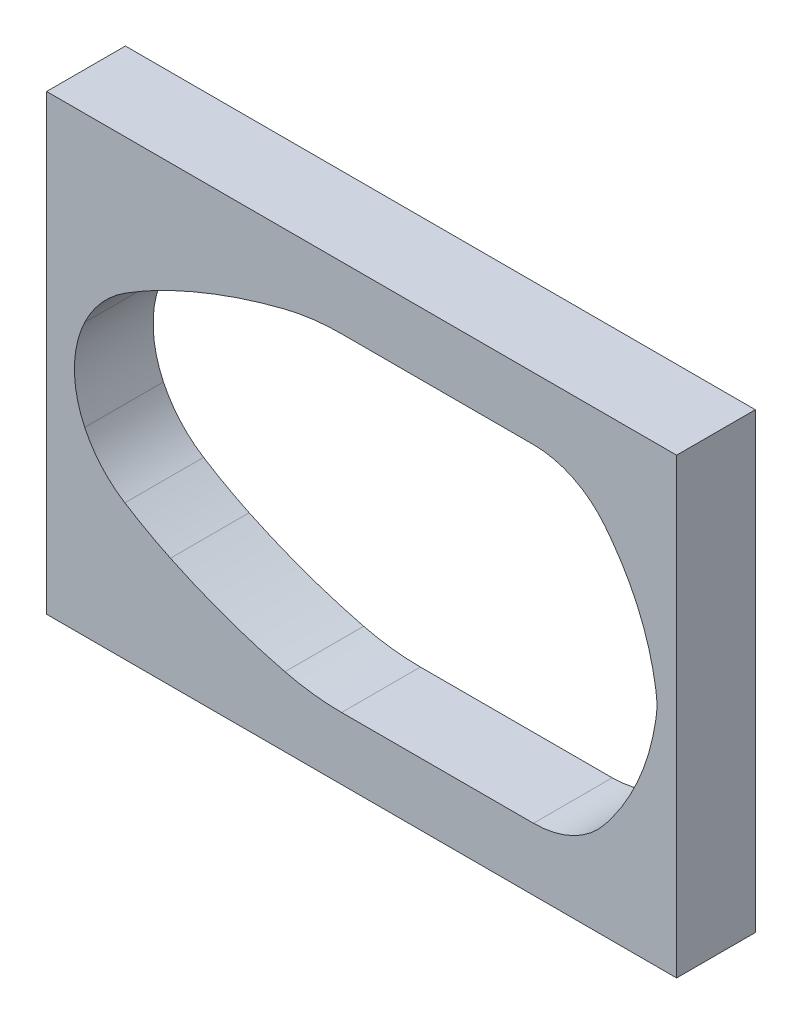
from build123d import *

# Parameters (mm, degrees)
SKETCH_4_W          = 160
SKETCH_4_H          = 115
EXTRUDE_1_DEPTH     = 20
CUT_EXTRUDE_1_DEPTH = 20
SKETCH_16_R         = 5.5
CUT_EXTRUDE_2_DEPTH = 15


with BuildPart() as part:
    # 草圖4 → 填料-伸長1 (new body)
    with BuildSketch(Plane.XY):
        with Locations((14.659712787, 72.59909222)):
            Rectangle(SKETCH_4_W, SKETCH_4_H)
    extrude(amount=EXTRUDE_1_DEPTH)

    # 草圖2 → 除料-伸長1 (cut)
    with BuildSketch(Plane.XY):
        with BuildLine():
            Line((9.582154386, 114.239387395), (32.639572719, 114.239387395))
            Line((32.639572719, 114.239387395), (35.911975242, 114.239387395))
            Line((35.911975242, 114.239387395), (58.302252446, 114.239387395))
            ThreePointArc((58.302252446, 114.239387395), (68.354977159, 111.933757574), (76.3981894, 105.477757274))
            ThreePointArc((76.3981894, 105.477757274), (77.386875553, 104.202213525), (78.350890948, 102.907923572))
            ThreePointArc((78.350890948, 102.907923572), (85.469179447, 90.183153699), (89.343429579, 76.126838912))
            Line((89.343429579, 76.126838912), (89.450916797, 75.407862922))
            ThreePointArc((89.450916797, 75.407862922), (89.659712787, 72.59909222), (89.450916797, 69.790321519))
            Line((89.450916797, 69.790321519), (89.343429579, 69.071345528))
            ThreePointArc((89.343429579, 69.071345528), (85.469179447, 55.015030741), (78.350890948, 42.290260868))
            ThreePointArc((78.350890948, 42.290260868), (77.386875553, 40.995970915), (76.3981894, 39.720427166))
            ThreePointArc((76.3981894, 39.720427166), (68.354977159, 33.264426866), (58.302252446, 30.958797045))
            Line((58.302252446, 30.958797045), (35.911975242, 30.958797045))
            Line((35.911975242, 30.958797045), (32.639572719, 30.958797045))
            Line((32.639572719, 30.958797045), (9.582154386, 30.958797045))
            ThreePointArc((9.582154386, 30.958797045), (2.328045496, 31.402381927), (-4.817967678, 32.726526576))
            ThreePointArc((-4.817967678, 32.726526576), (-19.619782039, 37.212171907), (-33.900352311, 43.151871824))
            ThreePointArc((-33.900352311, 43.151871824), (-39.787433986, 46.173940455), (-45.481740166, 49.545217155))
            ThreePointArc((-45.481740166, 49.545217155), (-51.391366265, 54.573313812), (-55.677619443, 61.041193705))
            ThreePointArc((-55.677619443, 61.041193705), (-58.292337425, 72.59909222), (-55.677619443, 84.156990735))
            ThreePointArc((-55.677619443, 84.156990735), (-51.391366265, 90.624870628), (-45.481740166, 95.652967285))
            ThreePointArc((-45.481740166, 95.652967285), (-39.787433986, 99.024243985), (-33.900352311, 102.046312617))
            ThreePointArc((-33.900352311, 102.046312617), (-19.619782039, 107.986012534), (-4.817967678, 112.471657865))
            ThreePointArc((-4.817967678, 112.471657865), (2.328045496, 113.795802514), (9.582154386, 114.239387395))
        make_face()
    extrude(amount=CUT_EXTRUDE_1_DEPTH, mode=Mode.SUBTRACT)

    # 草圖16 → 除料-伸長2 (cut)
    with BuildSketch(Plane(origin=(-66.2, 0, 0), x_dir=(0, 0, -1), z_dir=(1, 0, 0))):
        with Locations((-10, 120.09909222)):
            Circle(SKETCH_16_R)
        with Locations((-10, 105.09909222)):
            Circle(SKETCH_16_R)
        with Locations((-10, 40.09909222)):
            Circle(SKETCH_16_R)
        with Locations((-10, 25.09909222)):
            Circle(SKETCH_16_R)
    extrude(amount=CUT_EXTRUDE_2_DEPTH, mode=Mode.SUBTRACT)


solid = part.part
